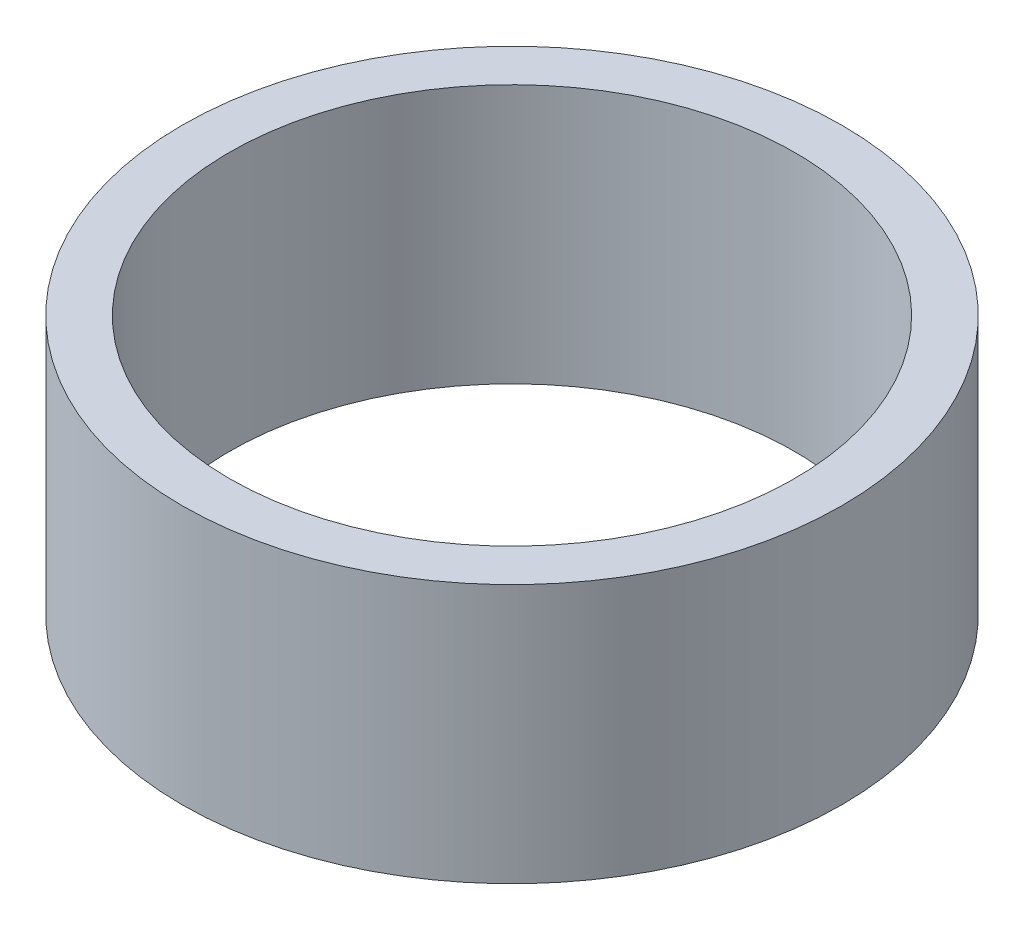
from build123d import *

# Parameters (mm, degrees)
SKETCH1_R           = 28
SKETCH1_R_2         = 24
BOSS_EXTRUDE1_DEPTH = 22


with BuildPart() as part:
    # Sketch1 → Boss-Extrude1 (new body)
    with BuildSketch(Plane(origin=(0, 0, 0), x_dir=(1, 0, 0), z_dir=(0, 1, 0))):
        Circle(SKETCH1_R)
        Circle(SKETCH1_R_2, mode=Mode.SUBTRACT)
    extrude(amount=BOSS_EXTRUDE1_DEPTH)


solid = part.part
